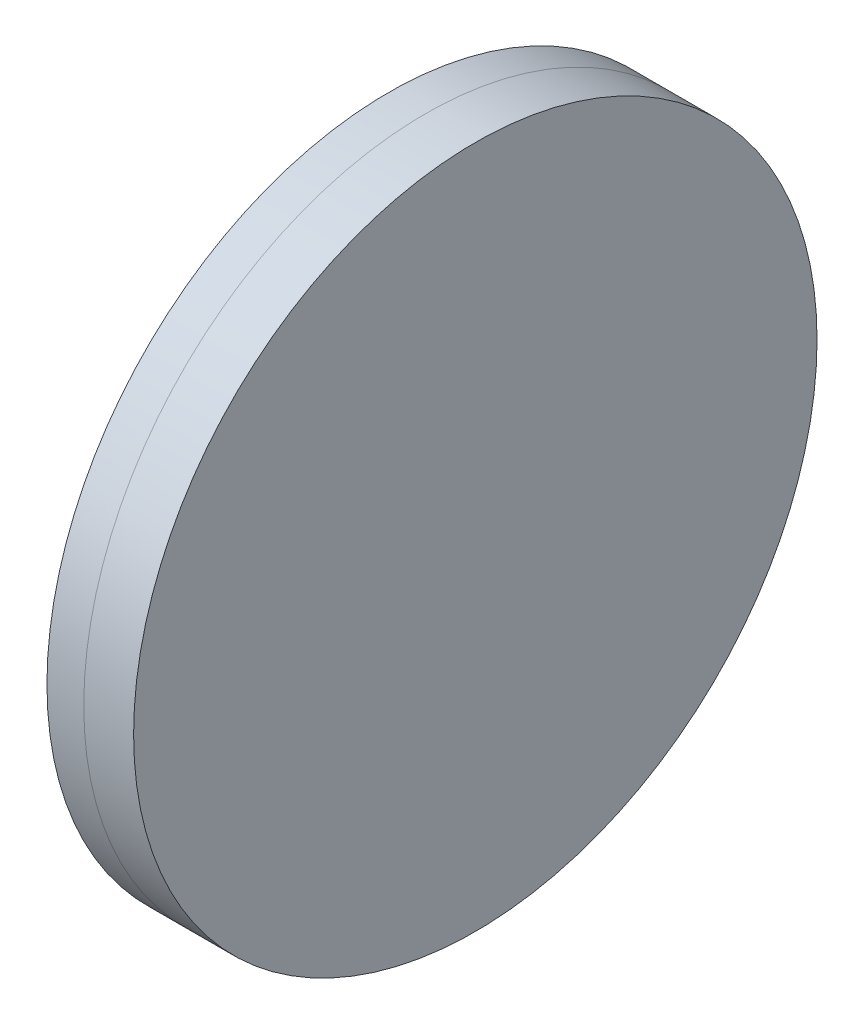
from build123d import *


with BuildPart() as part:
    # 草图1 one side → 旋转1 (revolve)
    with BuildSketch(Plane(origin=(0, 0, 0), x_dir=(1, 0, 0), z_dir=(0, 1, 0)), mode=Mode.PRIVATE) as revolve_1_sk:
        with BuildLine():
            ThreePointArc((73.202106875, 25.4), (72.712360592, 12.704196644), (72.549075872, 0))
            Line((72.549075872, 0), (76.749075872, 0))
            ThreePointArc((76.749075872, 0), (76.546242887, 12.706473982), (75.937950622, 25.4))
            Line((75.937950622, 25.4), (73.202106875, 25.4))
        make_face()
    revolve(revolve_1_sk.sketch.rotate(Axis((-402.021265573, 0, 0), (1, 0, 0)), 180), axis=Axis((-402.021265573, 0, 0), (1, 0, 0)))  # turned: the seam where the file's is


with BuildPart() as body_2:
    # 草图2 one side → 旋转3 (revolve)
    with BuildSketch(Plane(origin=(0, 0, 0), x_dir=(1, 0, 0), z_dir=(0, 1, 0)), mode=Mode.PRIVATE) as revolve_3_sk:
        with BuildLine():
            Line((79.642850406, 25.4), (75.937950622, 25.4))
            ThreePointArc((75.937950622, 25.4), (76.546242887, 12.706473982), (76.749075872, 0))
            Line((76.749075872, 0), (79.549075872, 0))
            ThreePointArc((79.549075872, 0), (79.572519585, 12.700086552), (79.642850406, 25.4))
        make_face()
    revolve(revolve_3_sk.sketch.rotate(Axis((-151.128475118, 0, 0), (1, 0, 0)), 180), axis=Axis((-151.128475118, 0, 0), (1, 0, 0)))  # turned: the seam where the file's is


solid = Compound([part.part, body_2.part])
